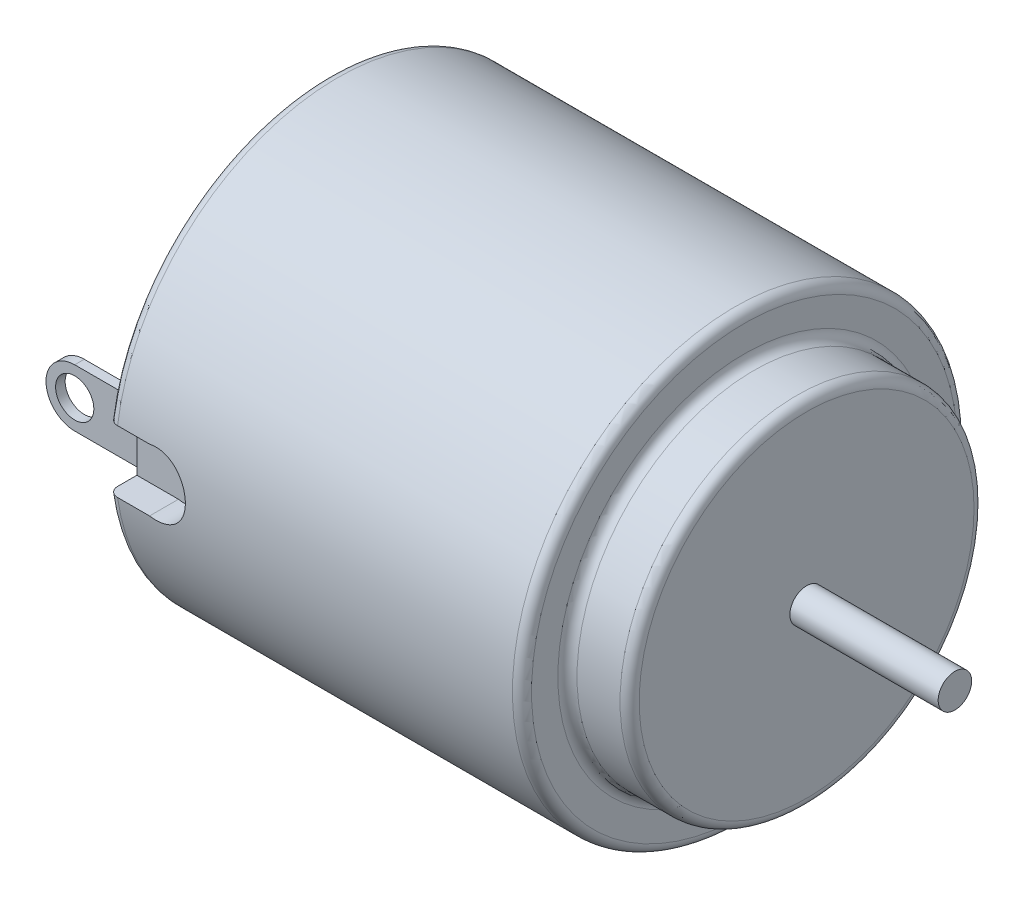
from build123d import *

# Parameters (mm, degrees)
SKETCH2_R           = 11.811
BOSS_EXTRUDE1_DEPTH = 25.4
SKETCH4_OUTSIDE_W   = 34.016
SKETCH4_OUTSIDE_H   = 34.016
SKETCH4_OUTSIDE_R   = 9.398
CUT_EXTRUDE1_DEPTH  = 3.302
FILLET1_R           = 0.508
SKETCH5_R           = 0.889
BOSS_EXTRUDE2_DEPTH = 7.874
CUT_EXTRUDE2_START  = 10.16
SKETCH8_R           = 1.684208496
SKETCH8_W           = 2.54
SKETCH8_H           = 3.302
CUT_EXTRUDE2_DEPTH  = 28.071149866
BOSS_EXTRUDE3_START = 9.398
SKETCH10_R          = 1.016
BOSS_EXTRUDE3_DEPTH = 0.508
CIRPATTERN1_COUNT   = 2


with BuildPart() as part:
    # Sketch2 → Boss-Extrude1 (new body)
    with BuildSketch(Plane(origin=(0, 0, 0), x_dir=(0, 0, -1), z_dir=(1, 0, 0))):
        Circle(SKETCH2_R)
    extrude(amount=BOSS_EXTRUDE1_DEPTH)

    # Sketch4 outside → Cut-Extrude1 (cut)
    with BuildSketch(Plane(origin=(25.4, 0, 0), x_dir=(0, 0, -1), z_dir=(1, 0, 0))):
        Rectangle(SKETCH4_OUTSIDE_W, SKETCH4_OUTSIDE_H)
        Circle(SKETCH4_OUTSIDE_R, mode=Mode.SUBTRACT)
    extrude(amount=-CUT_EXTRUDE1_DEPTH, mode=Mode.SUBTRACT)

    # Fillet1
    fillet1_edges = [part.edges().sort_by_distance(p)[0] for p in [
        (22.098, 0, 11.811),
        (25.4, 0, 9.398),
        (0, 0, 11.811),
        (22.098, 0, 9.398),
    ]]
    fillet(fillet1_edges, radius=FILLET1_R)

    # Sketch5 → Boss-Extrude2 (add)
    with BuildSketch(Plane(origin=(25.4, 0, 0), x_dir=(0, 0, -1), z_dir=(1, 0, 0))):
        Circle(SKETCH5_R)
    extrude(amount=BOSS_EXTRUDE2_DEPTH)

    # Sketch8 → Cut-Extrude2 (cut, through all)
    with BuildSketch(Plane.XY.offset(CUT_EXTRUDE2_START)):
        with Locations((2.54, 0)):
            Circle(SKETCH8_R)
        with Locations((1.27, 0)):
            Rectangle(SKETCH8_W, SKETCH8_H)
    extrude(amount=CUT_EXTRUDE2_DEPTH, mode=Mode.SUBTRACT)

    # Sketch10 → Boss-Extrude3 (add)
    with BuildSketch(Plane.XY.offset(BOSS_EXTRUDE3_START)):
        with BuildLine():
            Line((-3.556, -1.524), (0, -1.524))
            Line((0, -1.524), (0, 1.524))
            Line((0, 1.524), (-3.556, 1.524))
            ThreePointArc((-3.556, 1.524), (-5.08, 0), (-3.556, -1.524))
        make_face()
        with Locations((-3.556, 0)):
            Circle(SKETCH10_R, mode=Mode.SUBTRACT)
    boss_extrude3 = extrude(amount=BOSS_EXTRUDE3_DEPTH)

    # CirPattern1: Boss-Extrude3 ×2 about axis
    cirpattern1_axis = Axis((0, 0, 0), (1, 0, 0))
    for i in range(1, CIRPATTERN1_COUNT):
        add(boss_extrude3.rotate(cirpattern1_axis, i * 360 / CIRPATTERN1_COUNT))


solid = part.part
